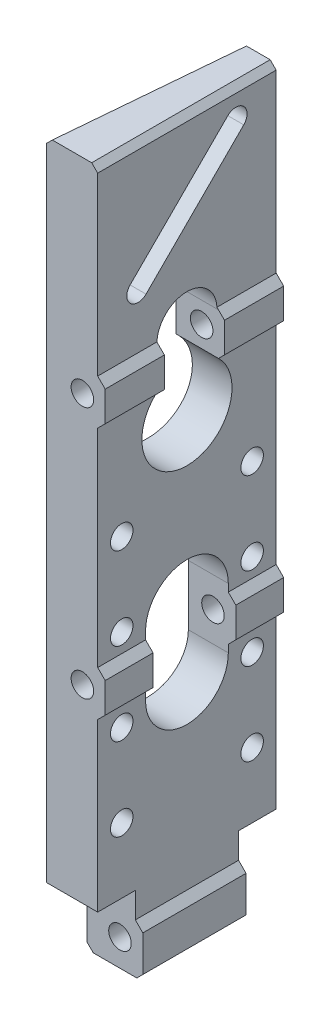
from build123d import *

# Parameters (mm, degrees)
BOSS_EXTRUDE1_DEPTH = 24.892
CUT_EXTRUDE8_DEPTH  = 25.892
CUT_EXTRUDE6_DEPTH  = 305.8
SKETCH9_R           = 4.7625
CUT_EXTRUDE7_DEPTH  = 76.2
SKETCH2_R           = 4.7625
CUT_EXTRUDE1_DEPTH  = 76.438
SKETCH3_R           = 4.7625
CUT_EXTRUDE2_DEPTH  = 60.5376
CUT_EXTRUDE9_DEPTH  = 25.892
CUT_EXTRUDE10_DEPTH = 76.438
SKETCH6_R           = 4.7625
CUT_EXTRUDE4_DEPTH  = 25.892
LPATTERN1_COUNT     = 3
LPATTERN1_PITCH     = 34.925
LPATTERN1_COL_COUNT = 2
LPATTERN1_COL_PITCH = 34.925
CHAMFER1_SIZE       = 2.54


with BuildPart() as part:
    # Sketch1 → Boss-Extrude1 (new body)
    with BuildSketch(Plane(origin=(0, 0, 0), x_dir=(0, 0, -1), z_dir=(1, 0, 0))):
        Polygon((0, 0), (0, 31.75), (-15.9004, 31.75), (-15.9004, 304.8), (59.5376, 304.8), (59.5376, 31.75), (43.6372, 31.75), (43.6372, 0), align=None)
    extrude(amount=BOSS_EXTRUDE1_DEPTH)

    # Sketch11 → Cut-Extrude8 (cut, through all)
    with BuildSketch(Plane(origin=(24.892, 0, 0), x_dir=(0, 0, -1), z_dir=(1, 0, 0))):
        with BuildLine():
            Line((39.3065, 124.46), (39.3065, 99.06))
            ThreePointArc((39.3065, 99.06), (21.8186, 81.5721), (4.3307, 99.06))
            Line((4.3307, 99.06), (4.3307, 124.46))
            ThreePointArc((4.3307, 124.46), (21.8186, 141.9479), (39.3065, 124.46))
        make_face()
        with BuildLine():
            Line((34.5186, 227.33), (34.5186, 209.55))
            ThreePointArc((34.5186, 209.55), (21.8186, 176.300968343), (9.1186, 209.55))
            Line((9.1186, 209.55), (9.1186, 227.33))
            ThreePointArc((9.1186, 227.33), (21.8186, 240.03), (34.5186, 227.33))
        make_face()
    extrude(amount=-CUT_EXTRUDE8_DEPTH, mode=Mode.SUBTRACT)

    # Sketch8 → Cut-Extrude6 (cut, through all)
    with BuildSketch(Plane(origin=(0, 0, 0), x_dir=(1, 0, 0), z_dir=(0, 1, 0))):
        Polygon((0, 59.5376), (6.599969799, 59.5376), (0, -15.9004), align=None)
    extrude(amount=CUT_EXTRUDE6_DEPTH, mode=Mode.SUBTRACT)

    # Sketch9 → Cut-Extrude7 (cut, symmetric)
    with BuildSketch(Plane.XY.offset(15.9004)):
        with Locations((15.24, 218.44)):
            Circle(SKETCH9_R)
    extrude(amount=CUT_EXTRUDE7_DEPTH, both=True, mode=Mode.SUBTRACT)

    # Sketch2 → Cut-Extrude1 (cut, through all)
    with BuildSketch(Plane.XY.offset(15.9004)):
        with Locations((15.24, 111.76)):
            Circle(SKETCH2_R)
    extrude(amount=-CUT_EXTRUDE1_DEPTH, mode=Mode.SUBTRACT)

    # Sketch3 → Cut-Extrude2 (cut, through all)
    with BuildSketch(Plane.XY):
        with Locations((15.24, 11.43)):
            Circle(SKETCH3_R)
    extrude(amount=-CUT_EXTRUDE2_DEPTH, mode=Mode.SUBTRACT)

    # Sketch12 → Cut-Extrude9 (cut, through all)
    with BuildSketch(Plane(origin=(24.892, 0, 0), x_dir=(0, 0, -1), z_dir=(1, 0, 0))):
        with BuildLine():
            Line((-2.203585124, 254.493006967), (39.105593033, 295.802185124))
            ThreePointArc((39.105593033, 295.802185124), (45.840785124, 295.802185124), (45.840785124, 289.066993033))
            Line((45.840785124, 289.066993033), (4.531606967, 247.757814876))
            ThreePointArc((4.531606967, 247.757814876), (-2.203585124, 247.757814876), (-2.203585124, 254.493006967))
        make_face()
    extrude(amount=-CUT_EXTRUDE9_DEPTH, mode=Mode.SUBTRACT)

    # Sketch13 → Cut-Extrude10 (cut, through all)
    with BuildSketch(Plane.XY.offset(15.9004)):
        Polygon((24.892, 304.8), (21.717, 304.8), (21.717, 227.965), (24.892, 224.79), align=None)
        Polygon((21.717, 121.285), (21.717, 208.915), (24.892, 212.09), (24.892, 118.11), align=None)
        Polygon((24.892, 17.78), (24.892, 105.41), (21.717, 102.235), (21.717, 20.955), align=None)
    extrude(amount=-CUT_EXTRUDE10_DEPTH, mode=Mode.SUBTRACT)

    # Sketch6 → Cut-Extrude4 (cut, through all)
    with BuildSketch(Plane(origin=(24.892, 0, 0), x_dir=(0, 0, -1), z_dir=(1, 0, 0))):
        with Locations((-5.7404, 94.2975)):
            Circle(SKETCH6_R)
        with Locations((49.3776, 94.2975)):
            Circle(SKETCH6_R)
    cut_extrude4 = extrude(amount=-CUT_EXTRUDE4_DEPTH, mode=Mode.SUBTRACT)

    # LPattern1: Cut-Extrude4 ×3
    with Locations(*[(0, i * LPATTERN1_PITCH, 0) for i in range(1, LPATTERN1_COUNT)]):
        add(cut_extrude4, mode=Mode.SUBTRACT)

    # LPattern1 col: Cut-Extrude4 ×2
    with Locations(*[(0, -i * LPATTERN1_COL_PITCH, 0) for i in range(1, LPATTERN1_COL_COUNT)]):
        add(cut_extrude4, mode=Mode.SUBTRACT)

    # Chamfer1
    chamfer1_edges = [part.edges().sort_by_distance(p)[0] for p in [
        (21.717, 304.8, -21.8186),
        (24.892, 0, -21.8186),
        (3.2999849, 0, -21.8186),
        (3.2999849, 304.8, -21.8186),
    ]]
    chamfer(chamfer1_edges, length=CHAMFER1_SIZE)


solid = part.part
